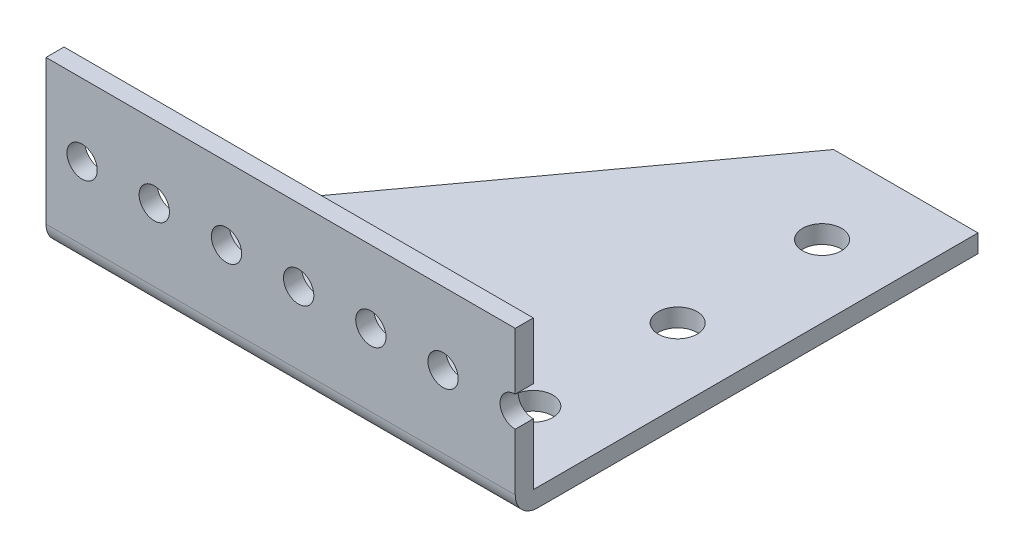
from build123d import *

# Parameters (mm, degrees)
BOSS_EXTRUDE1_START    = -34.925
SKETCH1_W              = 82.55
SKETCH1_H              = 81.407
BOSS_EXTRUDE1_DEPTH    = 3.175
SKETCH3_W              = 82.55
SKETCH3_H              = 3.175
BOSS_EXTRUDE2_DEPTH    = 50.8
F_10_CLEARANCE_HOLE2_D = 5.334
CHAMFER1_SIZE          = 3.175
FILLET2_R              = 3.937
SKETCH9_R              = 3.429
CUT_EXTRUDE2_DEPTH     = 54.975
SKETCH10_W             = 82.55
SKETCH10_H             = 24.638
CUT_EXTRUDE3_DEPTH     = 82.407


with BuildPart() as part:
    # Sketch1 → Boss-Extrude1 (new body)
    with BuildSketch(Plane(origin=(0, 0, 0), x_dir=(1, 0, 0), z_dir=(0, 1, 0)).offset(BOSS_EXTRUDE1_START)):
        Rectangle(SKETCH1_W, SKETCH1_H)
    extrude(amount=BOSS_EXTRUDE1_DEPTH)

    # Sketch3 → Boss-Extrude2 (add)
    with BuildSketch(Plane(origin=(0, -31.75, 0), x_dir=(1, 0, 0), z_dir=(0, 1, 0))):
        with Locations((0, -39.116)):
            Rectangle(SKETCH3_W, SKETCH3_H)
    extrude(amount=BOSS_EXTRUDE2_DEPTH)

    # #10 Clearance Hole2 (through all)
    with Locations(Plane(origin=(0, 0, -40.7035), x_dir=(-1, 0, 0), z_dir=(0, 0, -1))):
        with Locations((22.225, 7.112), (9.525, 7.112), (-3.175, 7.112), (-15.875, 7.112), (-28.575, 7.112), (22.225, -18.288), (9.525, -18.288), (-3.175, -18.288), (-15.875, -18.288), (-28.575, -18.288), (34.925, 7.112), (34.925, -18.288), (-41.275, 7.112), (-41.275, -18.288)):
            Hole(F_10_CLEARANCE_HOLE2_D / 2)

    # Chamfer1
    chamfer1_edges = [part.edges().sort_by_distance(p)[0] for p in [
        (-41.275, 19.05, 39.116),
    ]]
    chamfer(chamfer1_edges, length=CHAMFER1_SIZE)

    # Fillet2
    fillet2_edges = [part.edges().sort_by_distance(p)[0] for p in [
        (0, -34.925, 40.7035),
    ]]
    fillet(fillet2_edges, radius=FILLET2_R)

    # Sketch9 → Cut-Extrude2 (cut, through all)
    with BuildSketch(Plane.XZ.offset(34.925)):
        with Locations((28.575, 24.8285)):
            Circle(SKETCH9_R)
        with Locations((28.575, -0.5715)):
            Circle(SKETCH9_R)
        with Locations((28.575, -25.9715)):
            Circle(SKETCH9_R)
        Polygon((-41.275, 37.5285), (15.875, -40.7035), (-41.275, -40.7035), align=None)
    extrude(amount=-CUT_EXTRUDE2_DEPTH, mode=Mode.SUBTRACT)

    # Sketch10 → Cut-Extrude3 (cut, through all)
    with BuildSketch(Plane.XY.offset(40.7035)):
        with Locations((0, 6.731)):
            Rectangle(SKETCH10_W, SKETCH10_H)
    extrude(amount=-CUT_EXTRUDE3_DEPTH, mode=Mode.SUBTRACT)


solid = part.part
